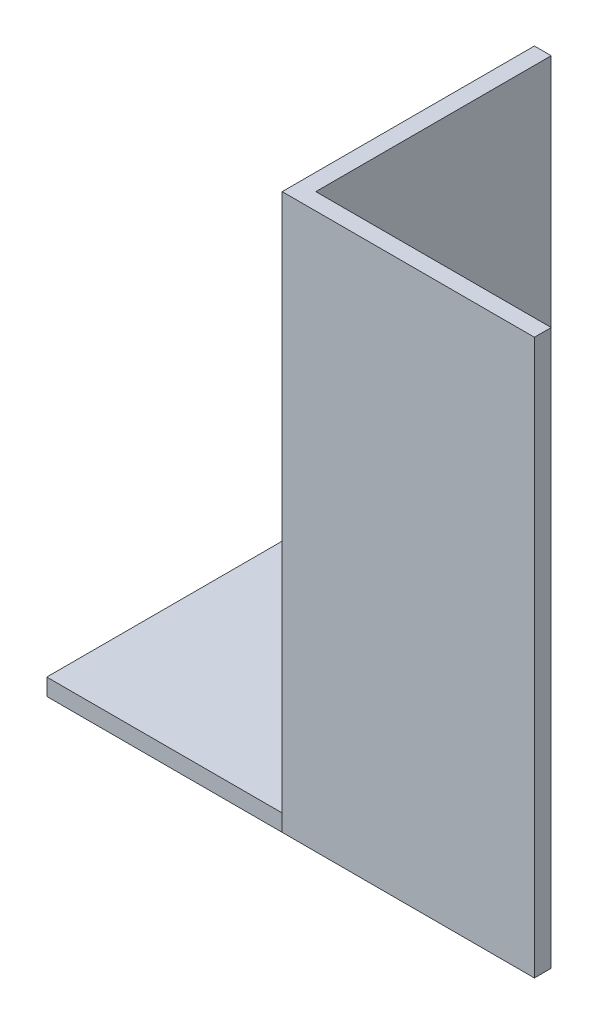
from build123d import *

# Parameters (mm, degrees)
EXTRUDE_1_DEPTH     = 53
CUT_EXTRUDE_2_DEPTH = 20
SKETCH_5_W          = 14
SKETCH_5_H          = 1
EXTRUDE_2_DEPTH     = 16


with BuildPart() as part:
    # Эскиз1 → Бобышка-Вытянуть1 (new body)
    with BuildSketch(Plane(origin=(0, 0, 0), x_dir=(1, 0, 0), z_dir=(0, 1, 0))):
        Polygon((0, 0), (0, 15), (1, 15), (1, 1), (15, 1), (15, 0), align=None)
    extrude(amount=EXTRUDE_1_DEPTH)

    # Эскиз3 → Вырез-Вытянуть2 (cut)
    with BuildSketch(Plane.XZ):
        Polygon((15, 0), (0, 0), (0, -15), (1, -15), (1, -1), (15, -1), align=None)
    extrude(amount=-CUT_EXTRUDE_2_DEPTH, mode=Mode.SUBTRACT)

    # Эскиз5 → Бобышка-Вытянуть2 (add)
    with BuildSketch(Plane(origin=(1, 0, 0), x_dir=(0, 0, -1), z_dir=(1, 0, 0))):
        with Locations((8, 19.5)):
            Rectangle(SKETCH_5_W, SKETCH_5_H)
    extrude(amount=-EXTRUDE_2_DEPTH)


solid = part.part
